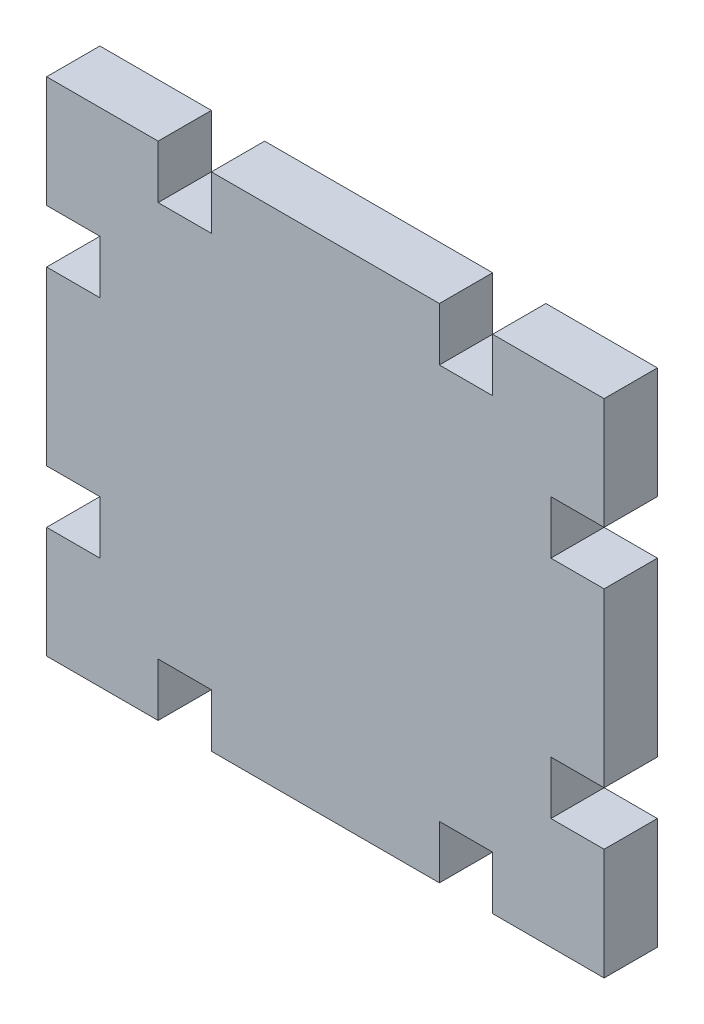
from build123d import *

# Parameters (mm, degrees)
BOSS_EXTRUDE1_DEPTH = 4.7752


with BuildPart() as part:
    # Sketch3 → Boss-Extrude1 (new body)
    with BuildSketch(Plane.XY):
        Polygon((10, 0), (10, 4.7752), (14.7752, 4.7752), (14.7752, 0), (25, 0), (35.2248, 0), (35.2248, 4.7752), (40, 4.7752), (40, 0), (50, 0), (50, 10), (45.2248, 10), (45.2248, 14.7752), (50, 14.7752), (50, 22.5), (50, 30.2248), (45.2248, 30.2248), (45.2248, 35), (50, 35), (50, 45), (40, 45), (40, 40.2248), (35.2248, 40.2248), (35.2248, 45), (14.7752, 45), (14.7752, 40.2248), (10, 40.2248), (10, 45), (0, 45), (0, 35), (4.7752, 35), (4.7752, 30.2248), (0, 30.2248), (0, 14.7752), (4.7752, 14.7752), (4.7752, 10), (0, 10), (0, 0), align=None)
    extrude(amount=-BOSS_EXTRUDE1_DEPTH)


solid = part.part
